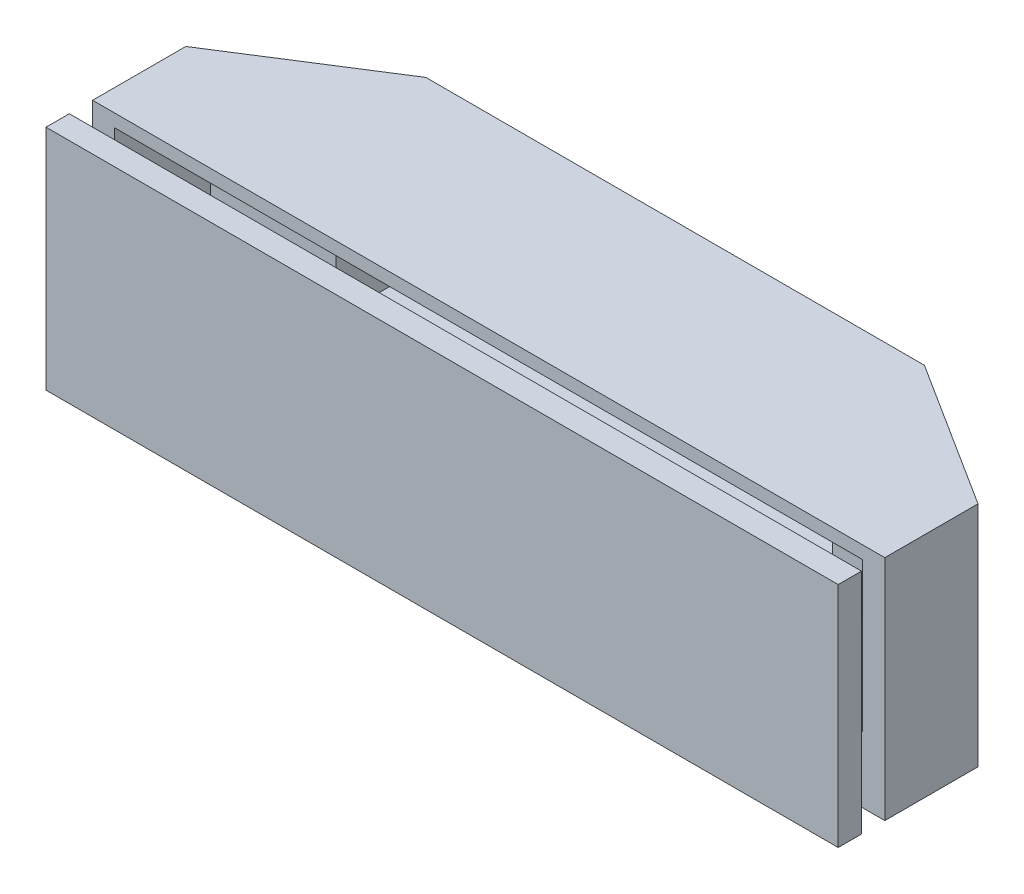
from build123d import *

# Parameters (mm, degrees)
BOSS_EXTRUDE1_DEPTH      = 7.5
BOSS_EXTRUDE1_DEPTH_BACK = 12.05
SKETCH1_W                = 42.6
SKETCH1_H                = 12.8
CUT_EXTRUDE1_DEPTH       = 7.2
SKETCH1_2_W              = 42.6
SKETCH1_2_H              = 12.8
CUT_EXTRUDE2_DEPTH       = 37.960677854
SKETCH3_W                = 64.2
SKETCH3_H                = 12.8
CUT_EXTRUDE3_DEPTH       = 8.2
BOSS_EXTRUDE2_START      = 2
SKETCH4_W                = 68
SKETCH4_H                = 19.55
BOSS_EXTRUDE2_DEPTH      = 2


with BuildPart() as part:
    # Sketch2 → Boss-Extrude1 (new, two sides: drawn at the far end of the back side and taken through both)
    with BuildSketch(Plane(origin=(0, 0, 0), x_dir=(1, 0, 0), z_dir=(0, 1, 0)).offset(-BOSS_EXTRUDE1_DEPTH_BACK)):
        Polygon((-34, 0.055383753), (-21.4, 8.055383753), (21.4, 8.055383753), (34, 0.055383753), (34, -7.944616247), (-34, -7.944616247), align=None)
    extrude(amount=BOSS_EXTRUDE1_DEPTH + BOSS_EXTRUDE1_DEPTH_BACK)

    # Sketch1 → Cut-Extrude1 (cut)
    with BuildSketch(Plane.XY):
        Rectangle(SKETCH1_W, SKETCH1_H)
    extrude(amount=-CUT_EXTRUDE1_DEPTH, mode=Mode.SUBTRACT)

    # Sketch1_2 → Cut-Extrude2 (cut, through all)
    with BuildSketch(Plane.XY):
        Rectangle(SKETCH1_2_W, SKETCH1_2_H)
    extrude(amount=CUT_EXTRUDE2_DEPTH, mode=Mode.SUBTRACT)

    # Sketch3 → Cut-Extrude3 (cut)
    with BuildSketch(Plane.XY.offset(7.944616247)):
        Rectangle(SKETCH3_W, SKETCH3_H)
    extrude(amount=-CUT_EXTRUDE3_DEPTH, mode=Mode.SUBTRACT)


with BuildPart() as body_2:
    # Sketch4 → Boss-Extrude2 (new body)
    with BuildSketch(Plane.XY.offset(7.944616247).offset(BOSS_EXTRUDE2_START)):
        with Locations((0, -2.275)):
            Rectangle(SKETCH4_W, SKETCH4_H)
    extrude(amount=BOSS_EXTRUDE2_DEPTH)


solid = Compound([part.part, body_2.part])
